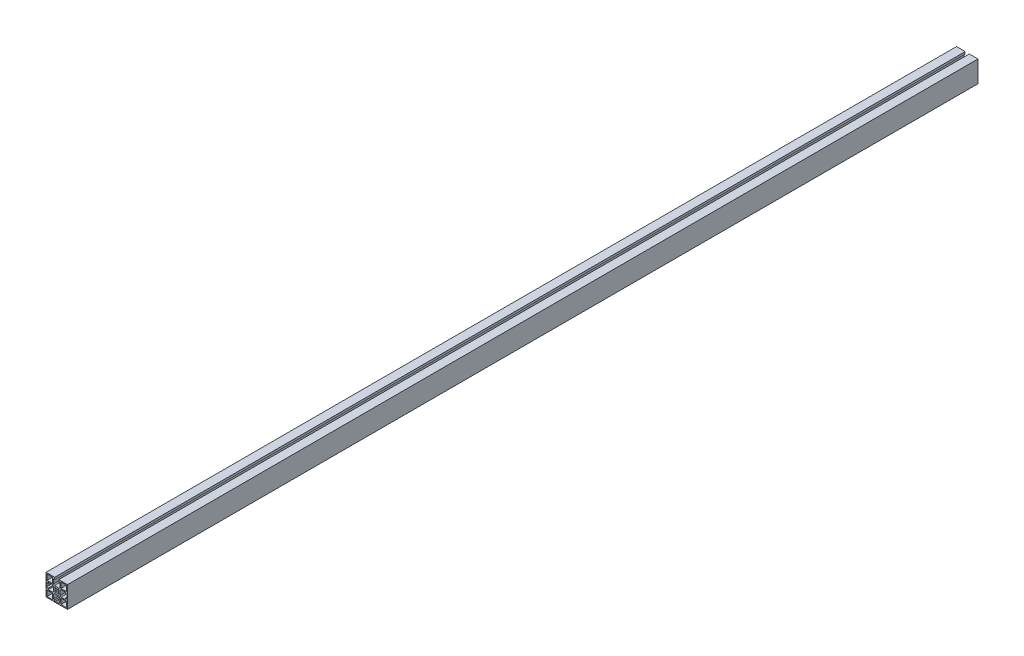
from build123d import *

# Parameters (mm, degrees)
SKETCH1_W           = 11.699975178
SKETCH1_H           = 11.699996949
SKETCH1_W_2         = 11.699990436
SKETCH1_H_2         = 11.699981689
SKETCH1_W_3         = 11.699990437
SKETCH1_H_3         = 11.699975177
SKETCH1_W_4         = 11.699981689
SKETCH1_H_4         = 11.699990436
BOSS_EXTRUDE1_DEPTH = 1907.794


with BuildPart() as part:
    # Sketch1 → Boss-Extrude1 (new body)
    with BuildSketch(Plane.XY):
        Polygon((-4.249491247, 17.999291576), (-4.249490956, 22.199304807), (-4.249490956, 22.499297883), (-22.499484399, 22.499298105), (-22.499484948, -22.500701346), (22.500514502, -22.500701895), (22.500515052, 22.499297556), (4.250509108, 22.499297779), (4.250509108, 22.199304487), (4.250508817, 17.999291575), (6.800527063, 17.999291575), (6.800526453, 9.199302988), (4.800526064, 7.199302969), (-4.799479817, 7.199303635), (-6.799479854, 9.199304042), (-6.799479244, 17.999291576), align=None)
        with Locations((-14.649542346, -14.650709384)):
            Rectangle(SKETCH1_W, SKETCH1_H, mode=Mode.SUBTRACT)
        with BuildLine():
            Line((-22.199510799, -4.250714391), (-22.199510799, -3.950696126))
            Line((-22.199510799, -3.950696126), (-21.731790056, -3.48300681))
            ThreePointArc((-21.731790056, -3.48300681), (-21.189814855, -2.671927844), (-20.999497617, -1.71518046))
            Line((-20.999497617, -1.71518046), (-20.999497617, 1.713721031))
            ThreePointArc((-20.999497617, 1.713721031), (-21.189799286, 2.670430863), (-21.731732544, 3.481489907))
            Line((-21.731732544, 3.481489907), (-22.199510888, 3.949267256))
            Line((-22.199510888, 3.949267256), (-22.199510888, 4.249285566))
            Line((-22.199510888, 4.249285566), (-17.999497356, 4.249285704))
            Line((-17.999497356, 4.249285704), (-17.999497356, 6.79927354))
            Line((-17.999497356, 6.79927354), (-9.199509947, 6.799273828))
            Line((-9.199509947, 6.799273828), (-7.199509956, 4.799274012))
            Line((-7.199509956, 4.799274012), (-7.199509641, -4.800732197))
            Line((-7.199509641, -4.800732197), (-9.199509449, -6.800732179))
            Line((-9.199509449, -6.800732179), (-17.99949762, -6.800732468))
            Line((-17.99949762, -6.800732468), (-17.99949762, -4.250714253))
            Line((-17.99949762, -4.250714253), (-22.199510799, -4.250714391))
        make_face(mode=Mode.SUBTRACT)
        with BuildLine():
            Line((-4.24949208, -18.000719999), (-6.799479919, -18.000719999))
            Line((-6.799479919, -18.000719999), (-6.799480207, -9.200732353))
            Line((-6.799480207, -9.200732353), (-4.799480391, -7.200732362))
            Line((-4.799480391, -7.200732362), (4.800525817, -7.200732047))
            Line((4.800525817, -7.200732047), (6.8005258, -9.200731855))
            Line((6.8005258, -9.200731855), (6.800526088, -18.000720263))
            Line((6.800526088, -18.000720263), (4.250507877, -18.000720263))
            Line((4.250507877, -18.000720263), (4.250508015, -22.200733153))
            Line((4.250508015, -22.200733153), (3.950489751, -22.200733153))
            Line((3.950489751, -22.200733153), (3.482800434, -21.73301241))
            ThreePointArc((3.482800434, -21.73301241), (2.671721468, -21.191037209), (1.714974084, -21.000719971))
            Line((1.714974084, -21.000719971), (-1.713927407, -21.000719971))
            ThreePointArc((-1.713927407, -21.000719971), (-2.670637239, -21.19102164), (-3.481696283, -21.732954898))
            Line((-3.481696283, -21.732954898), (-3.949473632, -22.200733242))
            Line((-3.949473632, -22.200733242), (-4.249491942, -22.200733242))
            Line((-4.249491942, -22.200733242), (-4.24949208, -18.000719999))
        make_face(mode=Mode.SUBTRACT)
        with Locations((14.65050626, -14.650767962)):
            Rectangle(SKETCH1_W_2, SKETCH1_H_2, mode=Mode.SUBTRACT)
        with BuildLine():
            Line((-3.181457266, -4.596908447), (-4.595670829, -3.182694885))
            Line((-4.595670829, -3.182694885), (-3.26221457, -1.849238626))
            ThreePointArc((-3.26221457, -1.849238626), (-3.749476751, -0.00071437), (-3.26221457, 1.847809887))
            Line((-3.26221457, 1.847809887), (-4.595670829, 3.181266146))
            Line((-4.595670829, 3.181266146), (-3.181457266, 4.595479708))
            Line((-3.181457266, 4.595479708), (-1.848001007, 3.262023449))
            ThreePointArc((-1.848001007, 3.262023449), (0.000523249, 3.74928563), (1.849047505, 3.262023449))
            Line((1.849047505, 3.262023449), (3.182503764, 4.595479708))
            Line((3.182503764, 4.595479708), (4.596717327, 3.181266146))
            Line((4.596717327, 3.181266146), (3.263261068, 1.847809887))
            ThreePointArc((3.263261068, 1.847809887), (3.750523249, -0.00071437), (3.263261068, -1.849238626))
            Line((3.263261068, -1.849238626), (4.596717327, -3.182694885))
            Line((4.596717327, -3.182694885), (3.182503764, -4.596908447))
            Line((3.182503764, -4.596908447), (1.849047505, -3.263452188))
            ThreePointArc((1.849047505, -3.263452188), (0.000523249, -3.75071437), (-1.848001007, -3.263452188))
            Line((-1.848001007, -3.263452188), (-3.181457266, -4.596908447))
        make_face(mode=Mode.SUBTRACT)
        with Locations((-14.64949028, 14.649335967)):
            Rectangle(SKETCH1_W_3, SKETCH1_H_3, mode=Mode.SUBTRACT)
        with BuildLine():
            Line((9.200519462, -6.800702567), (7.200519471, -4.800702751))
            Line((7.200519471, -4.800702751), (7.200519156, 4.799303458))
            Line((7.200519156, 4.799303458), (9.200518964, 6.79930344))
            Line((9.200518964, 6.79930344), (18.000507424, 6.799303729))
            Line((18.000507424, 6.799303729), (18.000507424, 4.249285514))
            Line((18.000507424, 4.249285514), (22.200520261, 4.249285652))
            Line((22.200520261, 4.249285652), (22.200520261, 3.949267391))
            Line((22.200520261, 3.949267391), (21.732799519, 3.481578075))
            ThreePointArc((21.732799519, 3.481578075), (21.190824318, 2.670499108), (21.000507079, 1.713751724))
            Line((21.000507079, 1.713751724), (21.000507079, -1.715149766))
            ThreePointArc((21.000507079, -1.715149766), (21.190808749, -2.671859599), (21.732742007, -3.482918643))
            Line((21.732742007, -3.482918643), (22.200520351, -3.950695992))
            Line((22.200520351, -3.950695992), (22.200520351, -4.250714302))
            Line((22.200520351, -4.250714302), (18.000507108, -4.25071444))
            Line((18.000507108, -4.25071444), (18.000507108, -6.800702279))
            Line((18.000507108, -6.800702279), (9.200519462, -6.800702567))
        make_face(mode=Mode.SUBTRACT)
        with Locations((14.650561583, 14.6492839)):
            Rectangle(SKETCH1_W_4, SKETCH1_H_4, mode=Mode.SUBTRACT)
    extrude(amount=BOSS_EXTRUDE1_DEPTH)


solid = part.part
